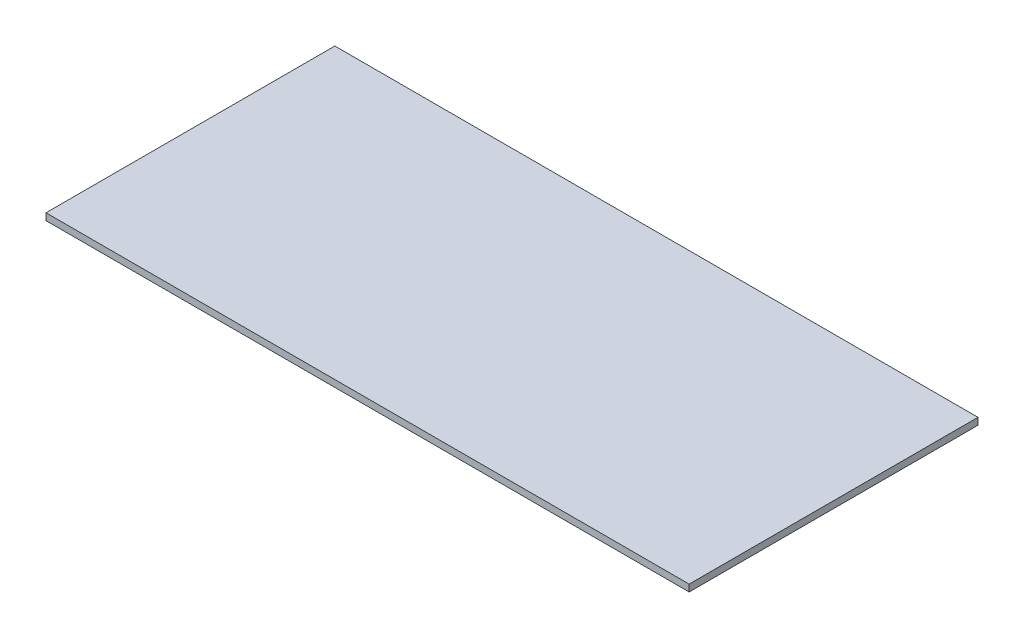
from build123d import *

# Parameters (mm, degrees)
SKETCH1_W           = 238.96344024
SKETCH1_H           = 107.318910288
BOSS_EXTRUDE1_DEPTH = 2.54


with BuildPart() as part:
    # Sketch1 → Boss-Extrude1 (new body)
    with BuildSketch(Plane(origin=(0, 0, 0), x_dir=(1, 0, 0), z_dir=(0, 1, 0))):
        Rectangle(SKETCH1_W, SKETCH1_H)
    extrude(amount=BOSS_EXTRUDE1_DEPTH)


solid = part.part
